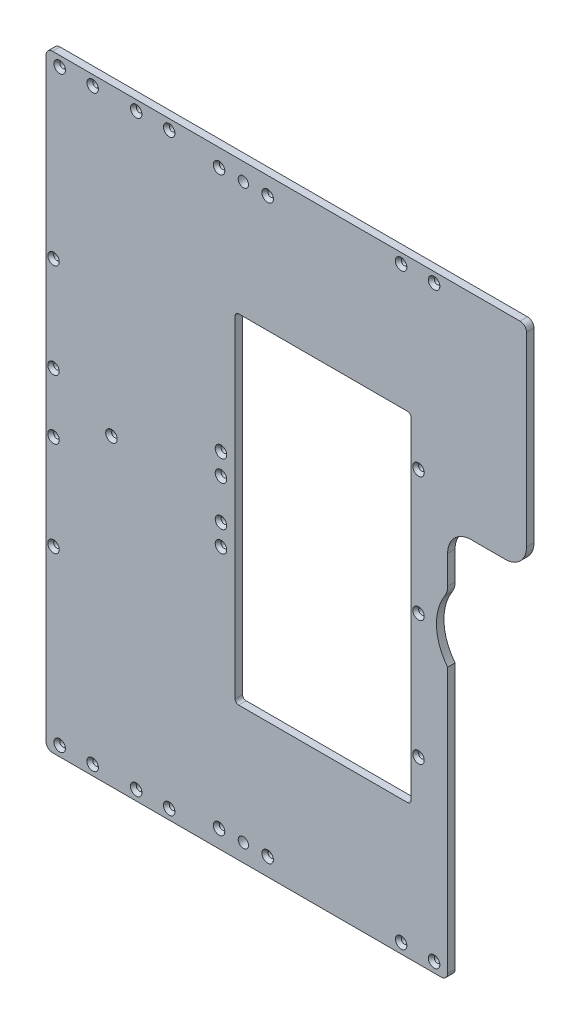
from build123d import *

# Parameters (mm, degrees)
BOSS_EXTRUDE1_DEPTH                             = 6.35
SKETCH2_W                                       = 149.3748
SKETCH2_H                                       = 287.7714167
CUT_EXTRUDE1_DEPTH                              = 7.35
FILLET1_R                                       = 3
CSK_FOR_10_FLAT_HEAD_MACHINE_SCREW2_D           = 5.1054
CSK_FOR_10_FLAT_HEAD_MACHINE_SCREW2_CSINK_D     = 9.779
CSK_FOR_10_FLAT_HEAD_MACHINE_SCREW2_CSINK_ANGLE = 82
CSK_FOR_10_FLAT_HEAD_MACHINE_SCREW1_D           = 5.1054
CSK_FOR_10_FLAT_HEAD_MACHINE_SCREW1_CSINK_D     = 9.779
CSK_FOR_10_FLAT_HEAD_MACHINE_SCREW1_CSINK_ANGLE = 82
CSK_FOR_10_FLAT_HEAD_MACHINE_SCREW3_D           = 5.1054
CSK_FOR_10_FLAT_HEAD_MACHINE_SCREW3_CSINK_D     = 9.779
CSK_FOR_10_FLAT_HEAD_MACHINE_SCREW3_CSINK_ANGLE = 82
CSK_FOR_10_FLAT_HEAD_MACHINE_SCREW5_D           = 4.9784
CSK_FOR_10_FLAT_HEAD_MACHINE_SCREW5_CSINK_D     = 9.779
CSK_FOR_10_FLAT_HEAD_MACHINE_SCREW5_CSINK_ANGLE = 82
F_5_16_CLEARANCE_HOLE1_D                        = 8.72998
FILLET2_R                                       = 5.5


with BuildPart() as part:
    # Sketch1 → Boss-Extrude1 (new body)
    with BuildSketch(Plane.XY):
        with BuildLine():
            Line((32.5, 94.5), (32.5, 258))
            Line((32.5, 258), (-375.6002, 258))
            Line((-375.6002, 258), (-375.6002, -258))
            Line((-375.6002, -258), (-34.5, -258))
            Line((-34.5, -258), (-34.5, -27.308423609))
            ThreePointArc((-34.5, -27.308423609), (-43.951223006, -2.071230621), (-36.915254237, 23.942932247))
            ThreePointArc((-36.915254237, 23.942932247), (-35.11648189, 27.849193214), (-34.5, 32.105295513))
            Line((-34.5, 32.105295513), (-34.5, 56.5))
            ThreePointArc((-34.5, 56.5), (-28.642135624, 70.642135624), (-14.5, 76.5))
            Line((-14.5, 76.5), (14.5, 76.5))
            ThreePointArc((14.5, 76.5), (27.227922061, 81.772077939), (32.5, 94.5))
        make_face()
    extrude(amount=BOSS_EXTRUDE1_DEPTH)

    # Sketch2 → Cut-Extrude1 (cut, through all)
    with BuildSketch(Plane(origin=(0, 0, 0), x_dir=(-1, 0, 0), z_dir=(0, 0, -1))):
        with Locations((140.2876, 0)):
            Rectangle(SKETCH2_W, SKETCH2_H)
    extrude(amount=-CUT_EXTRUDE1_DEPTH, mode=Mode.SUBTRACT)

    # Fillet1
    fillet1_edges = [part.edges().sort_by_distance(p)[0] for p in [
        (-65.6002, -143.88570835, 3.175),
        (-65.6002, 143.88570835, 3.175),
        (-214.975, 143.88570835, 3.175),
        (-214.975, -143.88570835, 3.175),
    ]]
    fillet(fillet1_edges, radius=FILLET1_R)

    # CSK for #10 Flat Head Machine Screw2 (through all)
    with Locations(Plane.XY.offset(6.35)):
        with Locations((-271, 249.5), (-299, 249.5), (-271, -249.5), (-299, -249.5), (-336, -249.5), (-364, -249.5), (-336, 249.5), (-364, 249.5), (-46, -249.5), (-74, -249.5), (-46, 249.5), (-74, 249.5)):
            CounterSinkHole(CSK_FOR_10_FLAT_HEAD_MACHINE_SCREW2_D / 2, CSK_FOR_10_FLAT_HEAD_MACHINE_SCREW2_CSINK_D / 2, counter_sink_angle=CSK_FOR_10_FLAT_HEAD_MACHINE_SCREW2_CSINK_ANGLE)

    # CSK for #10 Flat Head Machine Screw1 (through all)
    with Locations(Plane.XY.offset(6.35)):
        with Locations((-369.2375, 105.78570835), (-369.2375, 25.27849165), (-369.2375, -25.27849165), (-369.2375, -105.78570835), (-59.2375, 105.78570835), (-59.2375, 0), (-59.2375, -105.78570835)):
            CounterSinkHole(CSK_FOR_10_FLAT_HEAD_MACHINE_SCREW1_D / 2, CSK_FOR_10_FLAT_HEAD_MACHINE_SCREW1_CSINK_D / 2, counter_sink_angle=CSK_FOR_10_FLAT_HEAD_MACHINE_SCREW1_CSINK_ANGLE)

    # CSK for #10 Flat Head Machine Screw3 (through all)
    with Locations(Plane.XY.offset(6.35)):
        with Locations((-227, 17), (-320, 0), (-227, -35), (-227, -17), (-227, 35)):
            CounterSinkHole(CSK_FOR_10_FLAT_HEAD_MACHINE_SCREW3_D / 2, CSK_FOR_10_FLAT_HEAD_MACHINE_SCREW3_CSINK_D / 2, counter_sink_angle=CSK_FOR_10_FLAT_HEAD_MACHINE_SCREW3_CSINK_ANGLE)

    # CSK for #10 Flat Head Machine Screw5 (through all)
    with Locations(Plane.XY.offset(6.35)):
        with Locations((-228.6375, 243), (-187.3625, 243), (-187.3625, -243), (-228.6375, -243)):
            CounterSinkHole(CSK_FOR_10_FLAT_HEAD_MACHINE_SCREW5_D / 2, CSK_FOR_10_FLAT_HEAD_MACHINE_SCREW5_CSINK_D / 2, counter_sink_angle=CSK_FOR_10_FLAT_HEAD_MACHINE_SCREW5_CSINK_ANGLE)

    # 5/16 Clearance Hole1 (through all)
    with Locations(Plane.XY.offset(6.35)):
        with Locations((-208, 243), (-208, -243)):
            Hole(F_5_16_CLEARANCE_HOLE1_D / 2)

    # Fillet2
    fillet2_edges = [part.edges().sort_by_distance(p)[0] for p in [
        (-34.5, -258, 3.175),
        (-375.6002, -258, 3.175),
        (-375.6002, 258, 3.175),
        (32.5, 258, 3.175),
    ]]
    fillet(fillet2_edges, radius=FILLET2_R)


solid = part.part
